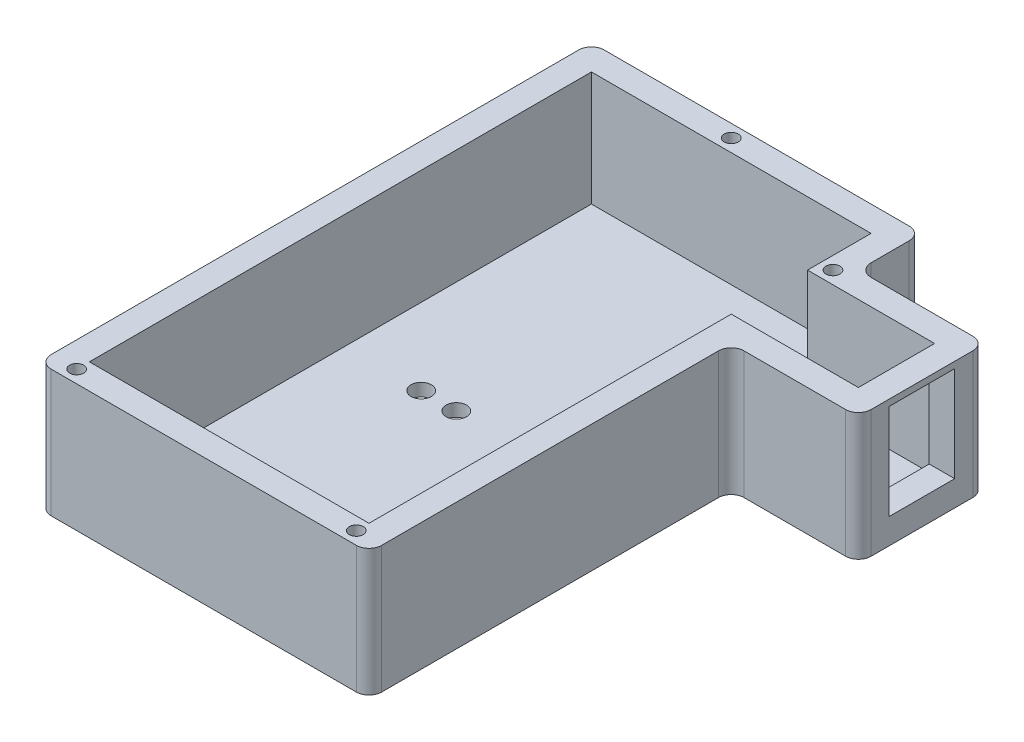
from build123d import *

# Parameters (mm, degrees)
BOSS_EXTRUDE1_DEPTH = 20
SKETCH2_W           = 44
SKETCH2_H           = 79
BATTERY_CUT_DEPTH   = 18
SKETCH3_W           = 20
SKETCH3_H           = 12
CUT_EXTRUDE2_DEPTH  = 18
SKETCH4_R           = 1.1
NUT_HOLES_DEPTH     = 10
SKETCH5_W           = 10.3
SKETCH5_H           = 15
CUT_EXTRUDE4_DEPTH  = 5
SKETCH6_R           = 1.6
CUT_EXTRUDE5_DEPTH  = 6
FILLET1_R           = 2


with BuildPart() as part:
    # Sketch1 → Boss-Extrude1 (new body)
    with BuildSketch(Plane(origin=(0, 0, 0), x_dir=(1, 0, 0), z_dir=(0, 1, 0))):
        Polygon((52, 77), (52, 87), (0, 87), (0, 0), (52, 0), (52, 57), (72, 57), (72, 77), align=None)
    extrude(amount=BOSS_EXTRUDE1_DEPTH)

    # Sketch2 → battery cut (cut)
    with BuildSketch(Plane(origin=(0, 20, 0), x_dir=(1, 0, 0), z_dir=(0, 1, 0))):
        with Locations((26, 43.5)):
            Rectangle(SKETCH2_W, SKETCH2_H)
    extrude(amount=-BATTERY_CUT_DEPTH, mode=Mode.SUBTRACT)

    # Sketch3 → Cut-Extrude2 (cut)
    with BuildSketch(Plane(origin=(0, 20, 0), x_dir=(1, 0, 0), z_dir=(0, 1, 0))):
        with Locations((58, 67)):
            Rectangle(SKETCH3_W, SKETCH3_H)
    extrude(amount=-CUT_EXTRUDE2_DEPTH, mode=Mode.SUBTRACT)

    # Sketch4 → nut holes (cut)
    with BuildSketch(Plane(origin=(0, 20, 0), x_dir=(1, 0, 0), z_dir=(0, 1, 0))):
        with Locations((4, 2)):
            Circle(SKETCH4_R)
        with Locations((48, 2)):
            Circle(SKETCH4_R)
        with Locations((24, 85)):
            Circle(SKETCH4_R)
        with Locations((50, 75)):
            Circle(SKETCH4_R)
    extrude(amount=-NUT_HOLES_DEPTH, mode=Mode.SUBTRACT)

    # Sketch5 → Cut-Extrude4 (cut)
    with BuildSketch(Plane(origin=(72, 0, 0), x_dir=(0, 0, -1), z_dir=(1, 0, 0))):
        with Locations((67, 11.5)):
            Rectangle(SKETCH5_W, SKETCH5_H)
    extrude(amount=-CUT_EXTRUDE4_DEPTH, mode=Mode.SUBTRACT)

    # Sketch6 → Cut-Extrude5 (cut)
    with BuildSketch(Plane(origin=(0, 2, 0), x_dir=(1, 0, 0), z_dir=(0, 1, 0))):
        with Locations((21.56, 44.18)):
            Circle(SKETCH6_R)
        with Locations((43.53, 44.18)):
            Circle(SKETCH6_R)
        with Locations((38, 44.18)):
            Circle(SKETCH6_R)
        with Locations((16.03, 44.18)):
            Circle(SKETCH6_R)
    extrude(amount=-CUT_EXTRUDE5_DEPTH, mode=Mode.SUBTRACT)

    # Fillet1
    fillet1_edges = [part.edges().sort_by_distance(p)[0] for p in [
        (0, 10, -87),
        (52, 10, -87),
        (52, 10, -77),
        (72, 10, -77),
        (72, 10, -57),
        (52, 10, -57),
        (52, 10, 0),
        (0, 10, 0),
    ]]
    fillet(fillet1_edges, radius=FILLET1_R)


solid = part.part
